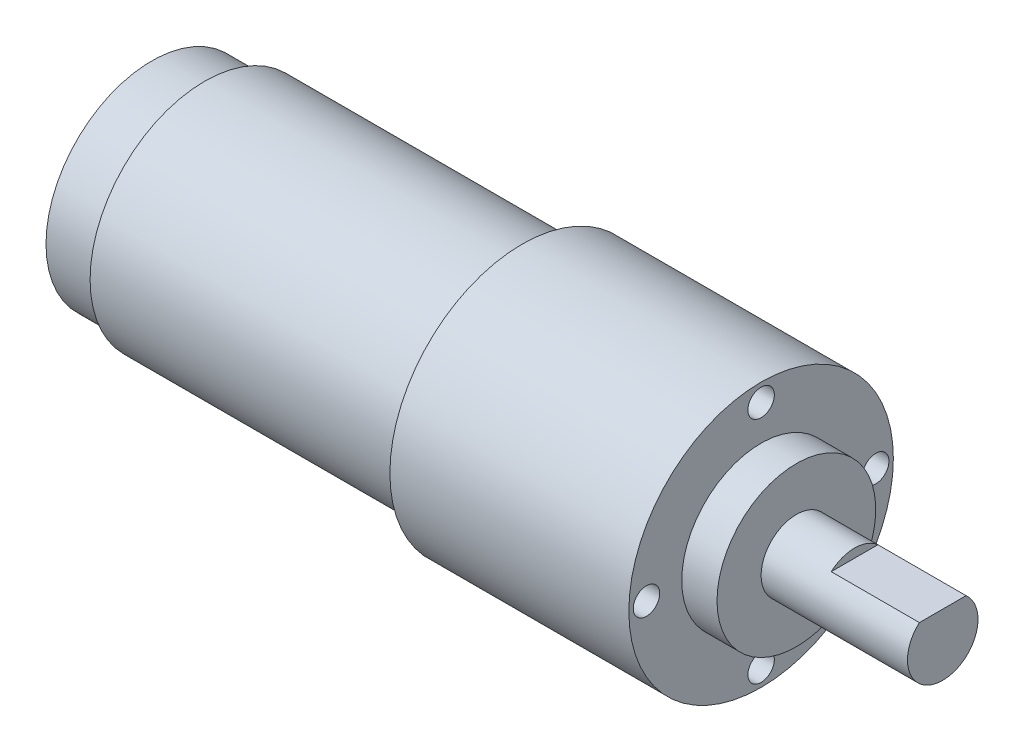
from build123d import *

# Parameters (mm, degrees)
ESQUISSE2_W             = 5.291502622
ESQUISSE2_H             = 1
ENL_V_MAT_EXTRU_1_DEPTH = 10
ESQUISSE3_R             = 1.5
FIXHOLES_DEPTH          = 3
REPEATFIXHOLES_COUNT    = 4


with BuildPart() as part:
    # Esquisse1 → MainRevolution (revolve)
    with BuildSketch(Plane.XY):
        Polygon((0, 0), (93.7, 0), (93.7, 4), (77.1, 4), (77.1, 9), (73.1, 9), (73.1, 15), (46, 15), (46, 13), (10, 13), (10, 12), (4, 12), (4, 2), (0, 2), align=None)
    revolve(axis=Axis((0, 0, 0), (1, 0, 0)))

    # Esquisse2 → Enlèv. mat.-Extru.1 (cut)
    with BuildSketch(Plane(origin=(93.7, 0, 0), x_dir=(0, 0, -1), z_dir=(1, 0, 0))):
        with Locations((0, 3.5)):
            Rectangle(ESQUISSE2_W, ESQUISSE2_H)
    extrude(amount=-ENL_V_MAT_EXTRU_1_DEPTH, mode=Mode.SUBTRACT)

    # Esquisse3 → FixHoles (cut)
    with BuildSketch(Plane(origin=(73.1, 0, 0), x_dir=(0, 0, -1), z_dir=(1, 0, 0))):
        with Locations((0, 13)):
            Circle(ESQUISSE3_R)
    fixholes = extrude(amount=-FIXHOLES_DEPTH, mode=Mode.SUBTRACT)

    # RepeatFixHoles: FixHoles ×4 about axis
    repeatfixholes_axis = Axis((-5.325, 0, 0), (1, 0, 0))
    for i in range(1, REPEATFIXHOLES_COUNT):
        add(fixholes.rotate(repeatfixholes_axis, i * 360 / REPEATFIXHOLES_COUNT), mode=Mode.SUBTRACT)


solid = part.part
